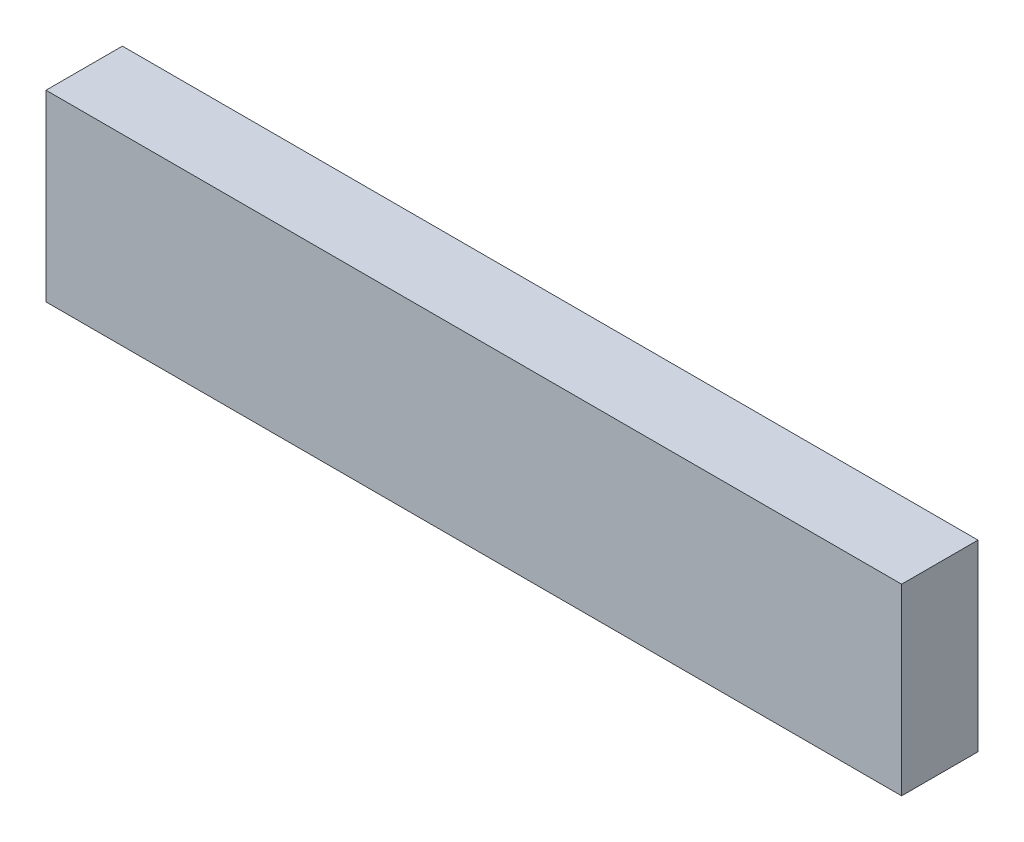
from build123d import *

# Parameters (mm, degrees)
SKETCH_1_W      = 56
SKETCH_1_H      = 12
EXTRUDE_1_DEPTH = 5


with BuildPart() as part:
    # 草圖1 → 填料-伸長1 (new body)
    with BuildSketch(Plane.XY):
        with Locations((-9.245982721, 9.41031941)):
            Rectangle(SKETCH_1_W, SKETCH_1_H)
    extrude(amount=EXTRUDE_1_DEPTH)


solid = part.part
